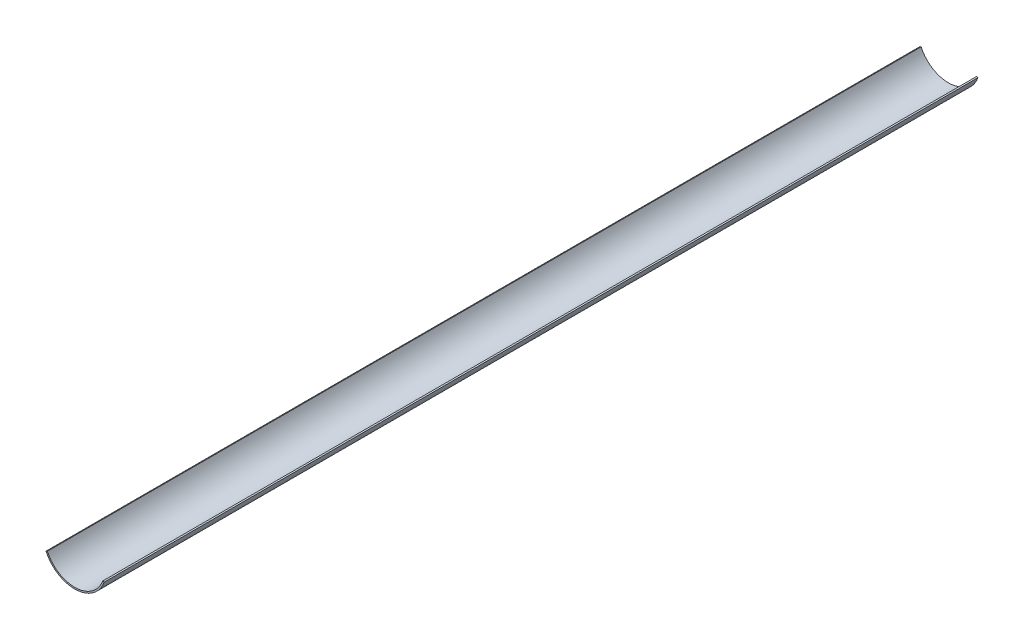
from build123d import *

# Parameters (mm, degrees)
BOSS_EXTRUDE1_DEPTH = 175


with BuildPart() as part:
    # Sketch1 → Boss-Extrude1 (new body)
    with BuildSketch(Plane.XY):
        with BuildLine():
            Line((-5.464372768, -2.478029511), (-5.739998257, -2.596480301))
            ThreePointArc((-5.739998257, -2.596480301), (0.249651411, -6.294995164), (5.927593448, -2.133758622))
            Line((5.927593448, -2.133758622), (5.62539731, -2.086840938))
            ThreePointArc((5.62539731, -2.086840938), (0.211516786, -5.996270562), (-5.464372768, -2.478029511))
        make_face()
    extrude(amount=BOSS_EXTRUDE1_DEPTH)


solid = part.part
